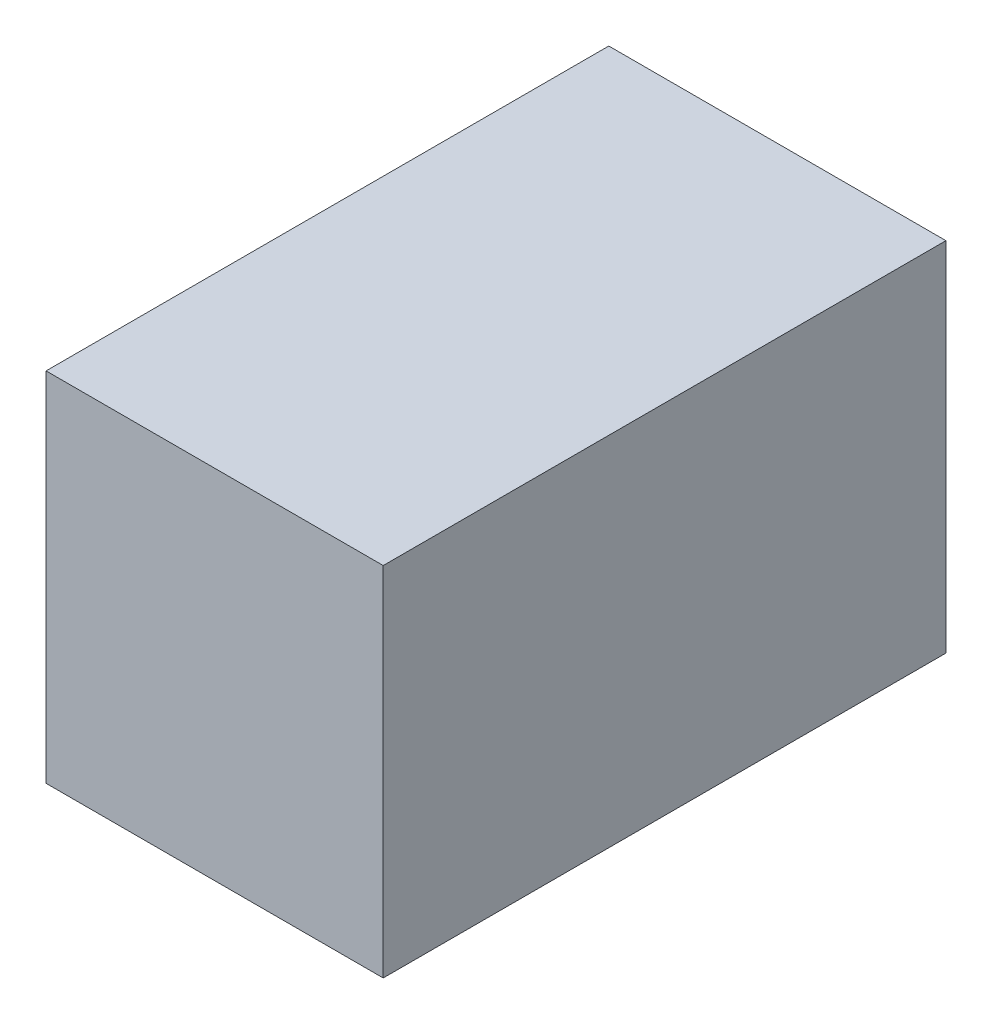
from build123d import *

# Parameters (mm, degrees)
SKETCH4_W           = 31.05
SKETCH4_H           = 18.25
BOSS_EXTRUDE1_DEPTH = 19
SHELL1_T            = 2
SKETCH5_W           = 12
SKETCH5_H           = 18.25
CUT_EXTRUDE1_DEPTH  = 2


with BuildPart() as part:
    # Sketch4 → Boss-Extrude1 (new body)
    with BuildSketch(Plane(origin=(0, 0, 0), x_dir=(0, 0, -1), z_dir=(1, 0, 0))):
        Rectangle(SKETCH4_W, SKETCH4_H)
    extrude(amount=BOSS_EXTRUDE1_DEPTH)

    # Shell1
    shell1_openings = [part.faces().sort_by_distance(p)[0] for p in [
        (0, 0, 0),
    ]]
    offset(amount=SHELL1_T, openings=shell1_openings, kind=Kind.INTERSECTION)

    # Sketch5 → Cut-Extrude1 (cut)
    with BuildSketch(Plane(origin=(0, 0, -17.525), x_dir=(-1, 0, 0), z_dir=(0, 0, -1))):
        with Locations((-6, 0)):
            Rectangle(SKETCH5_W, SKETCH5_H)
    extrude(amount=-CUT_EXTRUDE1_DEPTH, mode=Mode.SUBTRACT)


solid = part.part
